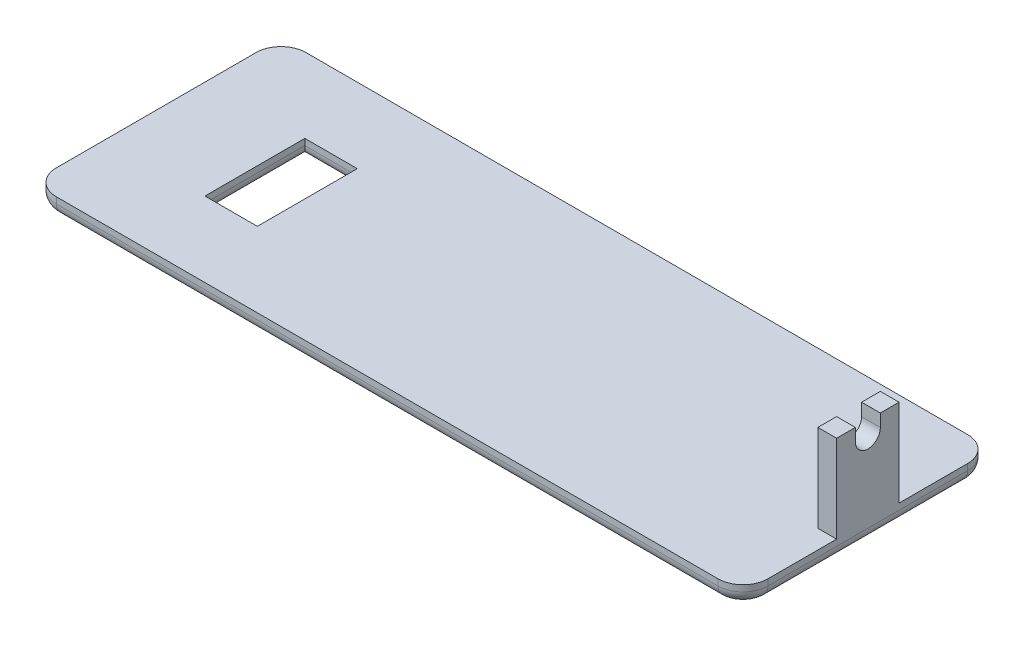
from build123d import *

# Parameters (mm, degrees)
SKETCH1_W           = 144.78
SKETCH1_H           = 50.8
BOSS_EXTRUDE1_DEPTH = 3.81
SKETCH2_W           = 3.81
SKETCH2_H           = 12.7
BOSS_EXTRUDE2_DEPTH = 17.78
CUT_EXTRUDE1_REACH  = 146.78
SKETCH4_W           = 10.668
SKETCH4_H           = 20.32
CUT_EXTRUDE2_DEPTH  = 22.59
FILLET3_R           = 5.08
FILLET4_R           = 2.54


with BuildPart() as part:
    # Sketch1 → Boss-Extrude1 (new body)
    with BuildSketch(Plane(origin=(0, 0, 0), x_dir=(1, 0, 0), z_dir=(0, 1, 0))):
        Rectangle(SKETCH1_W, SKETCH1_H)
    extrude(amount=BOSS_EXTRUDE1_DEPTH)

    # Sketch2 → Boss-Extrude2 (add)
    with BuildSketch(Plane(origin=(0, 3.81, 0), x_dir=(1, 0, 0), z_dir=(0, 1, 0))):
        with Locations((70.485, 0)):
            Rectangle(SKETCH2_W, SKETCH2_H)
    extrude(amount=BOSS_EXTRUDE2_DEPTH)

    # Sketch3 → Cut-Extrude1 (cut, up to next)
    with BuildSketch(Plane(origin=(72.39, 0, 0), x_dir=(0, 0, -1), z_dir=(1, 0, 0)), mode=Mode.PRIVATE) as cut_extrude1_sk1:
        with BuildLine():
            Line((-2.54, 21.59), (2.54, 21.59))
            Line((2.54, 21.59), (2.54, 19.05))
            ThreePointArc((2.54, 19.05), (0, 16.51), (-2.54, 19.05))
            Line((-2.54, 19.05), (-2.54, 21.59))
        make_face()
    cut_extrude1_tool1 = extrude(cut_extrude1_sk1.sketch, amount=-CUT_EXTRUDE1_REACH, mode=Mode.PRIVATE) & part.part
    add(cut_extrude1_tool1.solids().sort_by_distance((72.39, 19.287109, 0))[0], mode=Mode.SUBTRACT)

    # Sketch4 → Cut-Extrude2 (cut, through all)
    with BuildSketch(Plane.XZ):
        with Locations((-46.976, 0)):
            Rectangle(SKETCH4_W, SKETCH4_H)
    extrude(amount=-CUT_EXTRUDE2_DEPTH, mode=Mode.SUBTRACT)

    # Fillet3
    fillet3_edges = [part.edges().sort_by_distance(p)[0] for p in [
        (72.39, 1.905, 25.4),
        (-72.39, 1.905, 25.4),
        (-72.39, 1.905, -25.4),
        (72.39, 1.905, -25.4),
    ]]
    fillet(fillet3_edges, radius=FILLET3_R)

    # Fillet4
    fillet4_edges = [part.edges().sort_by_distance(p)[0] for p in [
        (-52.31, 0, 0),
        (-46.976, 0, -10.16),
        (-41.642, 0, 0),
        (-46.976, 0, 10.16),
        (-72.39, 0, 0),
        (72.39, 0, 0),
        (0, 0, 25.4),
        (0, 0, -25.4),
        (70.902102448, 0, -23.912102448),
        (70.902102448, 0, 23.912102448),
        (-70.902102448, 0, 23.912102448),
        (-70.902102448, 0, -23.912102448),
    ]]
    fillet(fillet4_edges, radius=FILLET4_R)


solid = part.part
